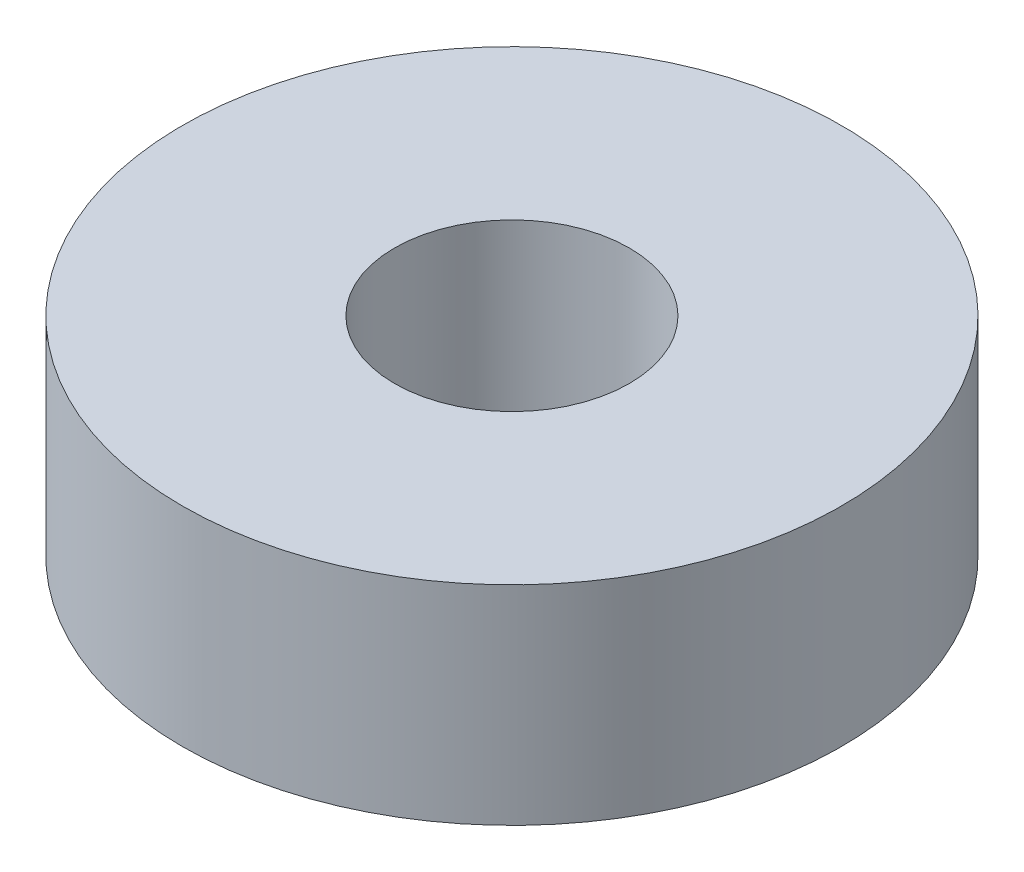
from build123d import *

# Parameters (mm, degrees)
SKETCH1_R           = 11.049
SKETCH1_R_2         = 3.937
BOSS_EXTRUDE1_DEPTH = 6.985


with BuildPart() as part:
    # Sketch1 → Boss-Extrude1 (new body)
    with BuildSketch(Plane(origin=(0, 0, 0), x_dir=(1, 0, 0), z_dir=(0, 1, 0))):
        Circle(SKETCH1_R)
        Circle(SKETCH1_R_2, mode=Mode.SUBTRACT)
    extrude(amount=BOSS_EXTRUDE1_DEPTH)


solid = part.part
